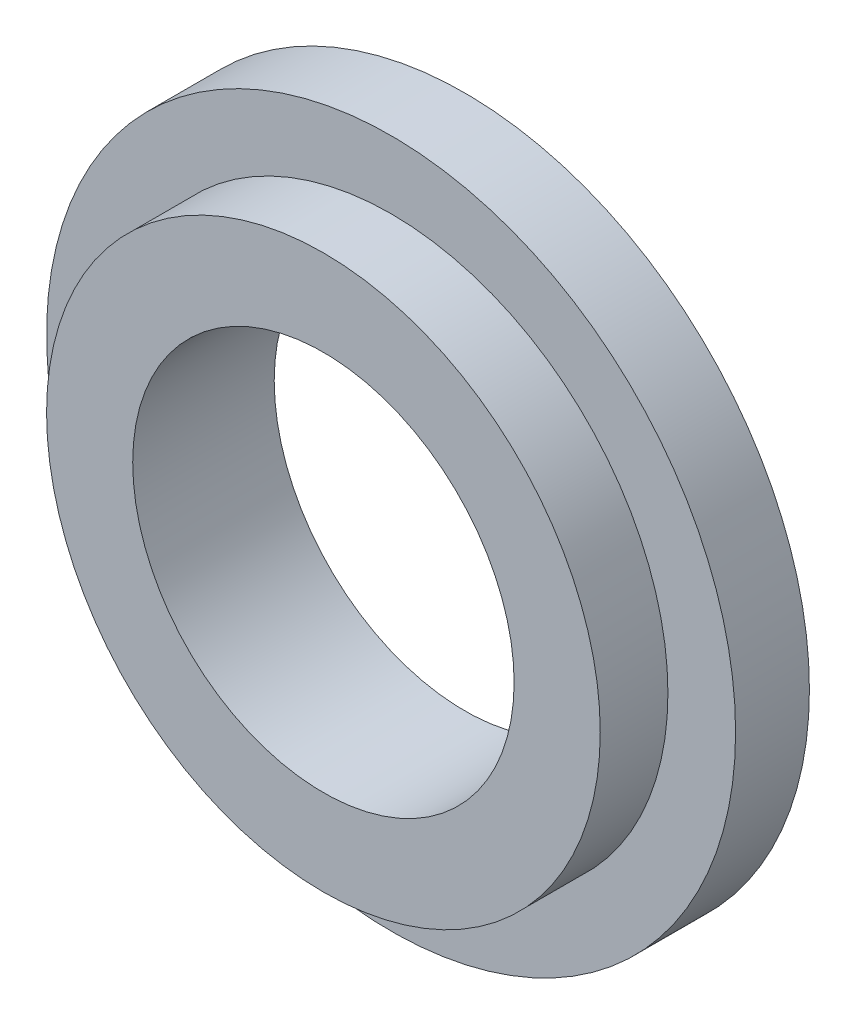
from build123d import *

# Parameters (mm, degrees)
ESQUISSE1_R             = 14
BOSS_EXTRU_1_DEPTH      = 3
ESQUISSE2_R             = 11.25
BOSS_EXTRU_2_DEPTH      = 2.75
ESQUISSE3_R             = 7.75
ENL_V_MAT_EXTRU_1_DEPTH = 5.75


with BuildPart() as part:
    # Esquisse1 → Boss.-Extru.1 (new body)
    with BuildSketch(Plane.XY):
        Circle(ESQUISSE1_R)
    extrude(amount=BOSS_EXTRU_1_DEPTH)

    # Esquisse2 → Boss.-Extru.2 (add)
    with BuildSketch(Plane.XY.offset(3)):
        Circle(ESQUISSE2_R)
    extrude(amount=BOSS_EXTRU_2_DEPTH)

    # Esquisse3 → Enlèv. mat.-Extru.1 (cut)
    with BuildSketch(Plane.XY.offset(5.75)):
        Circle(ESQUISSE3_R)
    extrude(amount=-ENL_V_MAT_EXTRU_1_DEPTH, mode=Mode.SUBTRACT)


solid = part.part
